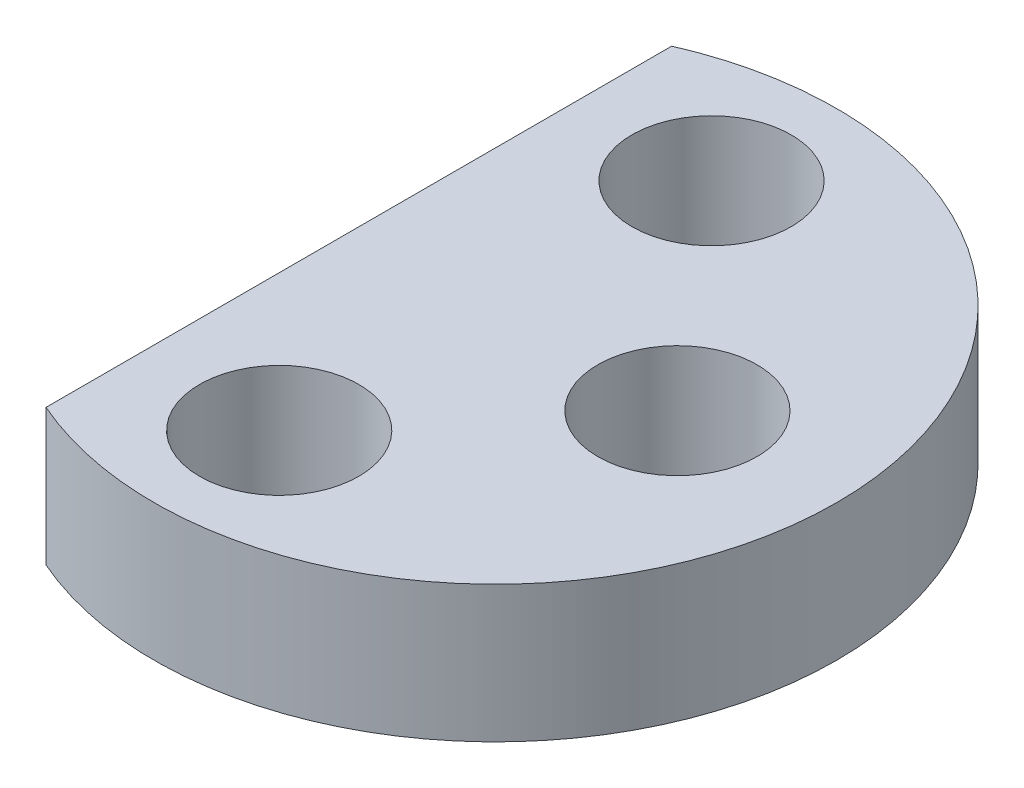
from build123d import *

# Parameters (mm, degrees)
SKETCH1_R           = 1.75
BOSS_EXTRUDE1_DEPTH = 3


with BuildPart() as part:
    # Sketch1 → Boss-Extrude1 (new body)
    with BuildSketch(Plane(origin=(0, 0, 0), x_dir=(1, 0, 0), z_dir=(0, 1, 0))):
        with BuildLine():
            Line((-3, 6.873863542), (-3, -6.873863542))
            ThreePointArc((-3, -6.873863542), (7.5, 0), (-3, 6.873863542))
        make_face()
        with Locations((0, 4.75)):
            Circle(SKETCH1_R, mode=Mode.SUBTRACT)
        with Locations((0, -4.75)):
            Circle(SKETCH1_R, mode=Mode.SUBTRACT)
        with Locations((4, 0)):
            Circle(SKETCH1_R, mode=Mode.SUBTRACT)
    extrude(amount=BOSS_EXTRUDE1_DEPTH)


solid = part.part
